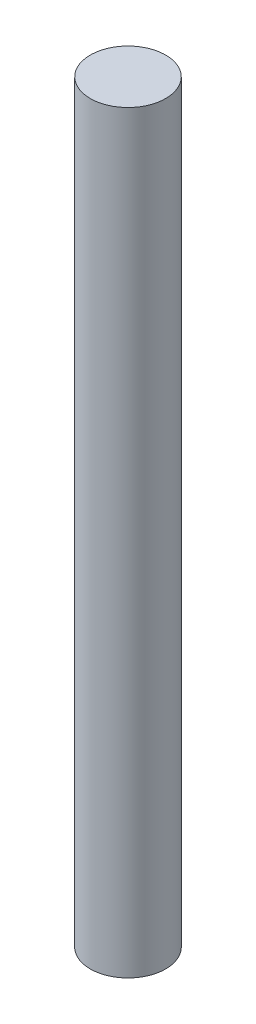
from build123d import *

# Parameters (mm, degrees)
ESBO_O1_R                = 10
RESSALTO_EXTRUS_O1_DEPTH = 200


with BuildPart() as part:
    # Esboço1 → Ressalto-extrusão1 (new body)
    with BuildSketch(Plane(origin=(0, 0, 0), x_dir=(1, 0, 0), z_dir=(0, 1, 0))):
        Circle(ESBO_O1_R)
    extrude(amount=RESSALTO_EXTRUS_O1_DEPTH)


solid = part.part
